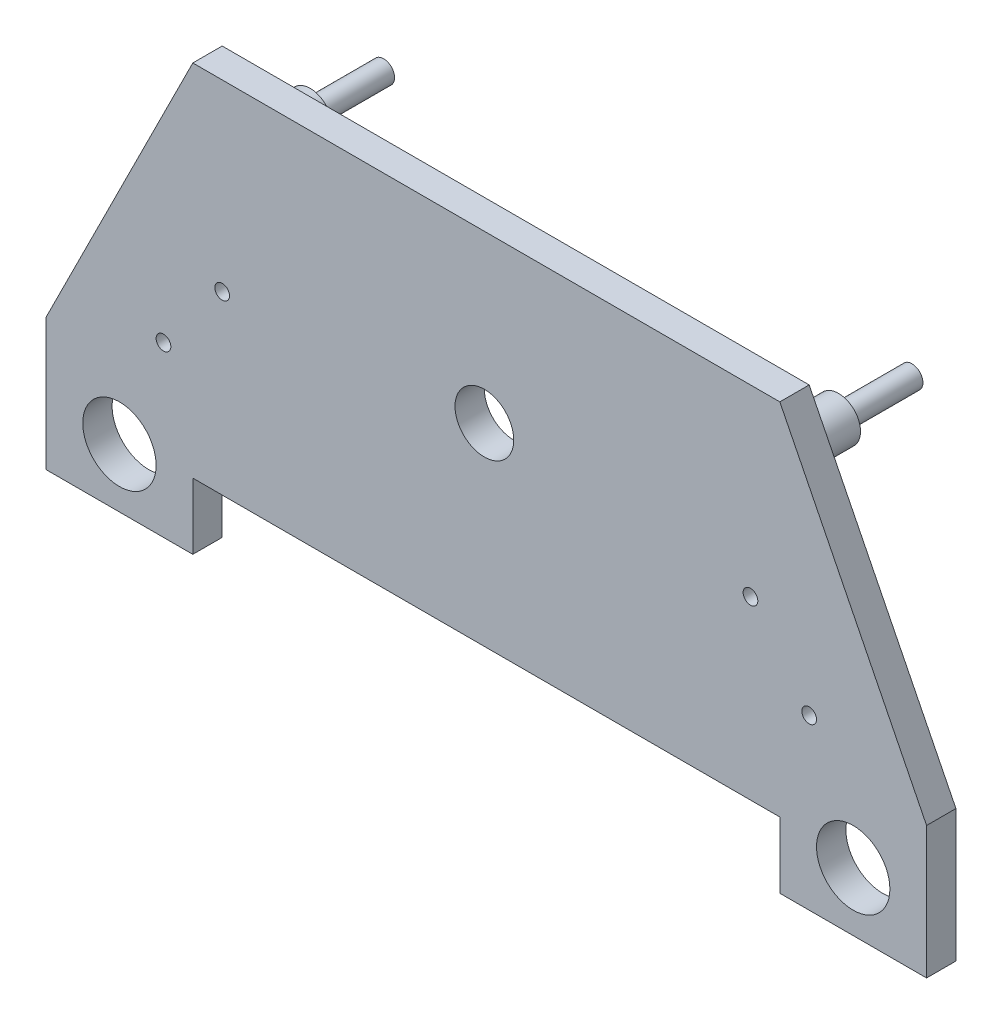
from build123d import *

# Parameters (mm, degrees)
EXTRUDE_1_DEPTH     = 2
SKETCH_2_R          = 2.5
CUT_EXTRUDE_3_DEPTH = 3
SKETCH_3_R          = 1.5
EXTRUDE_2_DEPTH     = 4
SKETCH_4_R          = 0.75
EXTRUDE_3_DEPTH     = 5
SKETCH_5_W          = 40
SKETCH_5_H          = 4.5
EXTRUDE_4_DEPTH     = 2
SKETCH_6_R          = 0.5
CUT_EXTRUDE_4_DEPTH = 1
SKETCH_7_R          = 2
CUT_EXTRUDE_5_DEPTH = 3


with BuildPart() as part:
    # 草图1 → 凸台-拉伸1 (new body)
    with BuildSketch(Plane.XY):
        Polygon((-21.685600323, 10.142561447), (18.314399677, 10.142561447), (28.314399677, -9.857438553), (28.314399677, -18.857438553), (18.314399677, -18.857438553), (18.314399677, -9.857438553), (-21.685600323, -9.857438553), (-21.685600323, -18.857438553), (-31.685600323, -18.857438553), (-31.685600323, -9.857438553), align=None)
    extrude(amount=EXTRUDE_1_DEPTH)

    # 草图2 → 切除-拉伸3 (cut, through all)
    with BuildSketch(Plane.XY):
        with Locations((-26.685600323, -14.857438553)):
            Circle(SKETCH_2_R)
        with Locations((23.314399677, -14.857438553)):
            Circle(SKETCH_2_R)
    extrude(amount=CUT_EXTRUDE_3_DEPTH, mode=Mode.SUBTRACT)

    # 草图3 → 凸台-拉伸2 (add)
    with BuildSketch(Plane(origin=(0, 0, 0), x_dir=(-1, 0, 0), z_dir=(0, 0, -1))):
        with Locations((-16.314399677, 5.142561447)):
            Circle(SKETCH_3_R)
        with Locations((19.685600323, 5.142561447)):
            Circle(SKETCH_3_R)
    extrude(amount=EXTRUDE_2_DEPTH)

    # 草图4 → 凸台-拉伸3 (add)
    with BuildSketch(Plane(origin=(0, 0, -4), x_dir=(-1, 0, 0), z_dir=(0, 0, -1))):
        with Locations((-16.314399677, 5.142561447)):
            Circle(SKETCH_4_R)
        with Locations((19.685600323, 5.142561447)):
            Circle(SKETCH_4_R)
    extrude(amount=EXTRUDE_3_DEPTH)

    # 草图5 → 凸台-拉伸4 (add)
    with BuildSketch(Plane.XY):
        with Locations((-1.685600323, -12.107438553)):
            Rectangle(SKETCH_5_W, SKETCH_5_H)
    extrude(amount=EXTRUDE_4_DEPTH)

    # 草图6 → 切除-拉伸4 (cut)
    with BuildSketch(Plane.XY.offset(2)):
        with Locations((-23.685600323, -7.357438553)):
            Circle(SKETCH_6_R)
        with Locations((20.314399677, -7.357438553)):
            Circle(SKETCH_6_R)
        with Locations((-19.685600323, -2.357438553)):
            Circle(SKETCH_6_R)
        with Locations((16.314399677, -2.357438553)):
            Circle(SKETCH_6_R)
    extrude(amount=-CUT_EXTRUDE_4_DEPTH, mode=Mode.SUBTRACT)

    # 草图7 → 切除-拉伸5 (cut, through all)
    with BuildSketch(Plane(origin=(0, 0, 0), x_dir=(-1, 0, 0), z_dir=(0, 0, -1))):
        with Locations((1.818081587, -1.181083472)):
            Circle(SKETCH_7_R)
    extrude(amount=-CUT_EXTRUDE_5_DEPTH, mode=Mode.SUBTRACT)


solid = part.part
